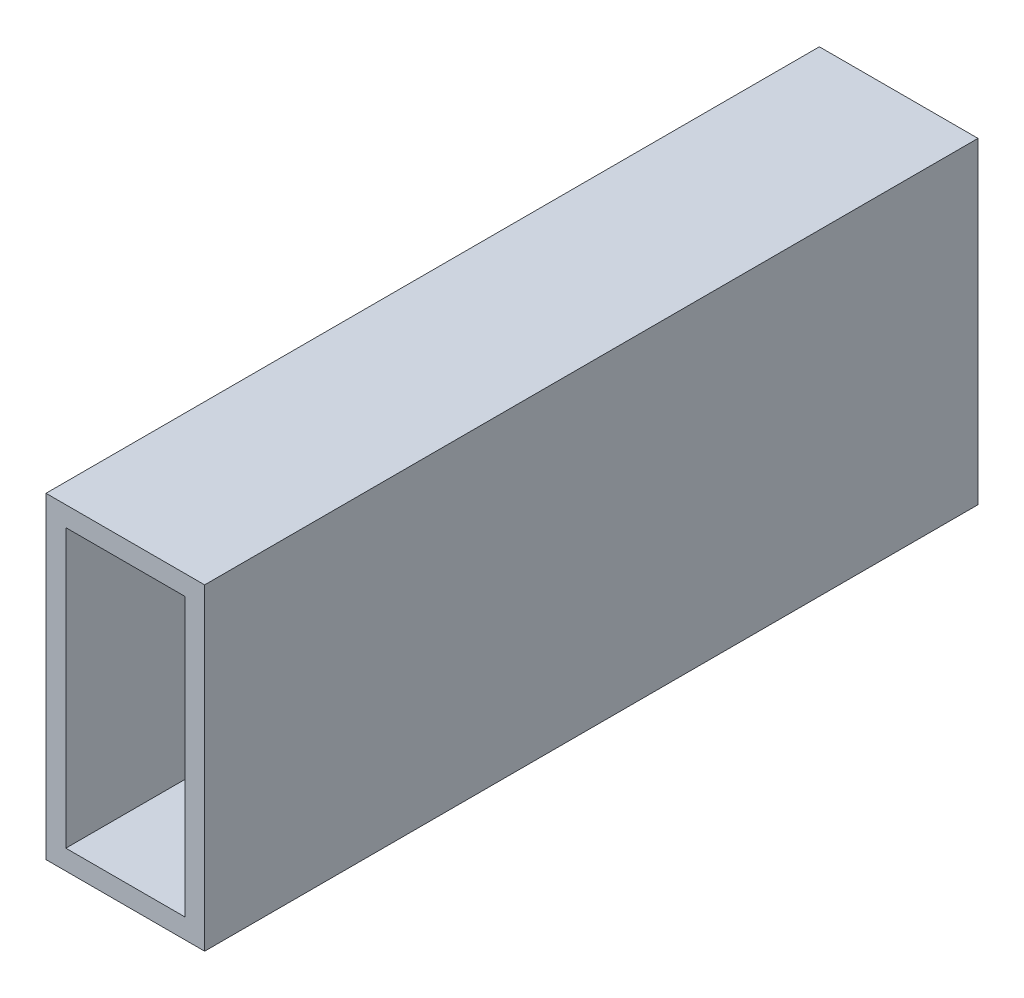
from build123d import *

# Parameters (mm, degrees)
SKETCH1_W           = 25.4
SKETCH1_H           = 50.8
BOSS_EXTRUDE1_DEPTH = 61.9125
SHELL1_T            = -3.175


with BuildPart() as part:
    # Sketch1 → Boss-Extrude1 (new body, symmetric)
    with BuildSketch(Plane.XY):
        Rectangle(SKETCH1_W, SKETCH1_H)
    extrude(amount=BOSS_EXTRUDE1_DEPTH, both=True)

    # Shell1
    shell1_openings = [part.faces().sort_by_distance(p)[0] for p in [
        (0, 0, 61.9125),
        (0, 0, -61.9125),
    ]]
    offset(amount=SHELL1_T, openings=shell1_openings, kind=Kind.INTERSECTION)


solid = part.part
